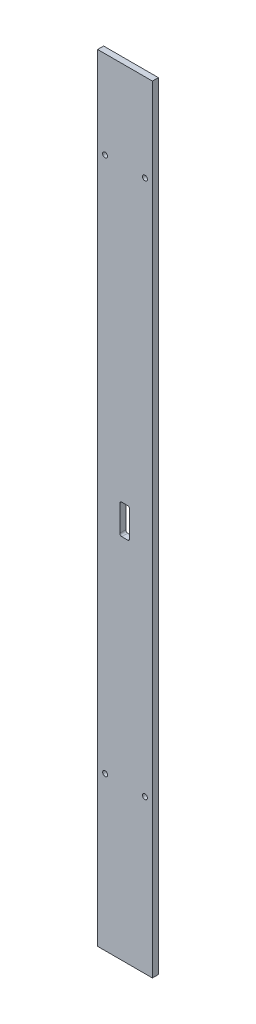
from build123d import *

# Parameters (mm, degrees)
SKETCH_1_W             = 55
SKETCH_1_H             = 780
EXTRUDE_1_DEPTH        = 3
CUT_EXTRUDE_1_DEPTH    = 7
HOLE_WIZARD_M6_1_D     = 5
HOLE_WIZARD_M6_1_DEPTH = 17
HOLE_WIZARD_M6_1_TIP   = 1.502151548


with BuildPart() as part:
    # 草图1 → 凸台-拉伸1 (new body, symmetric)
    with BuildSketch(Plane.XY):
        Rectangle(SKETCH_1_W, SKETCH_1_H)
    extrude(amount=EXTRUDE_1_DEPTH, both=True)

    # 草图4 → 切除-拉伸1 (cut, through all)
    with BuildSketch(Plane(origin=(0, 0, -3), x_dir=(-1, 0, 0), z_dir=(0, 0, -1))):
        with BuildLine():
            Line((3.251986045, -21.579414933), (-2.748013955, -21.579414933))
            ThreePointArc((-2.748013955, -21.579414933), (-4.162227517, -20.993628496), (-4.748013955, -19.579414933))
            Line((-4.748013955, -19.579414933), (-4.748013955, 6.420585067))
            ThreePointArc((-4.748013955, 6.420585067), (-4.162227517, 7.834798629), (-2.748013955, 8.420585067))
            Line((-2.748013955, 8.420585067), (3.251986045, 8.420585067))
            ThreePointArc((3.251986045, 8.420585067), (4.666199608, 7.834798629), (5.251986045, 6.420585067))
            Line((5.251986045, 6.420585067), (5.251986045, -19.579414933))
            ThreePointArc((5.251986045, -19.579414933), (4.666199608, -20.993628496), (3.251986045, -21.579414933))
        make_face()
    extrude(amount=-CUT_EXTRUDE_1_DEPTH, mode=Mode.SUBTRACT)

    # M6 螺纹孔1
    with Locations(Plane(origin=(0, 0, -3), x_dir=(-1, 0, 0), z_dir=(0, 0, -1))):
        with Locations((20, 302), (-20, 302), (20, -236), (-20, -236)):
            Hole(HOLE_WIZARD_M6_1_D / 2, depth=HOLE_WIZARD_M6_1_DEPTH)
            with Locations((0, 0, -(HOLE_WIZARD_M6_1_DEPTH + HOLE_WIZARD_M6_1_TIP / 2))):  # 118° drill point
                Cone(0, HOLE_WIZARD_M6_1_D / 2, HOLE_WIZARD_M6_1_TIP, mode=Mode.SUBTRACT)


solid = part.part
